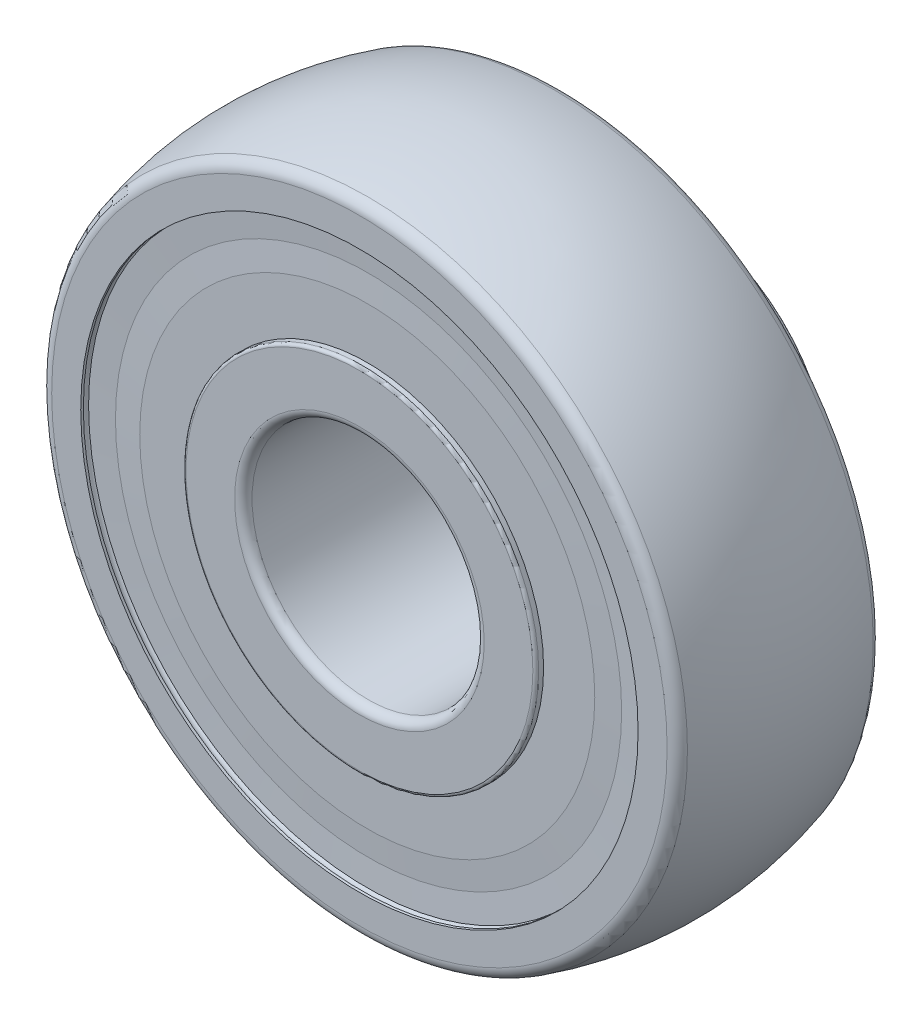
from build123d import *

# Parameters (mm, degrees)
BALL_PATTERN_COUNT              = 7
M3_SET_SCREW_HOLE_PATTERN_COUNT = 2
M3_SET_SCREW_HOLE_PATTERN_ANGLE = 90


with BuildPart() as part:
    # Sketch1 → Bearing Body (revolve)
    with BuildSketch(Plane(origin=(0, 0, 0), x_dir=(0, 0, -1), z_dir=(1, 0, 0))):
        with BuildLine():
            Line((-3.2, 4), (3.2, 4))
            Line((3.2, 4), (7.05, 4))
            ThreePointArc((7.05, 4), (7.262132034, 4.087867966), (7.35, 4.3))
            Line((7.35, 4.3), (7.35, 5.35))
            ThreePointArc((7.35, 5.35), (7.320710678, 5.420710678), (7.25, 5.45))
            Line((7.25, 5.45), (3.6, 5.45))
            Line((3.6, 5.45), (3.5, 5.55))
            Line((3.5, 5.55), (3.5, 5.975))
            ThreePointArc((3.5, 5.975), (3.470710678, 6.045710678), (3.4, 6.075))
            Line((3.4, 6.075), (3.23, 6.075))
            Line((3.23, 6.075), (3.23, 7.8375))
            Line((3.23, 7.8375), (3.185, 8.71875))
            Line((3.185, 8.71875), (3.23, 9.6))
            Line((3.23, 9.6), (3.14, 9.6))
            Line((3.14, 9.6), (3.05, 8.71875))
            Line((3.05, 8.71875), (3.05, 7.8375))
            Line((3.05, 7.8375), (3.14, 6.075))
            Line((3.14, 6.075), (1.520728526, 6.075))
            ThreePointArc((1.520728526, 6.075), (0, 5.3655), (-1.520728526, 6.075))
            Line((-1.520728526, 6.075), (-3.14, 6.075))
            Line((-3.14, 6.075), (-3.05, 7.8375))
            Line((-3.05, 7.8375), (-3.05, 8.71875))
            Line((-3.05, 8.71875), (-3.14, 9.6))
            Line((-3.14, 9.6), (-3.23, 9.6))
            Line((-3.23, 9.6), (-3.185, 8.71875))
            Line((-3.185, 8.71875), (-3.23, 7.8375))
            Line((-3.23, 7.8375), (-3.23, 6.075))
            Line((-3.23, 6.075), (-3.4, 6.075))
            ThreePointArc((-3.4, 6.075), (-3.470710678, 6.045710678), (-3.5, 5.975))
            Line((-3.5, 5.975), (-3.5, 4.3))
            ThreePointArc((-3.5, 4.3), (-3.412132034, 4.087867966), (-3.2, 4))
        make_face()
        with BuildLine():
            Line((-3.5, 9.6), (-3.5, 10.600290833))
            ThreePointArc((-3.5, 10.600290833), (-3.416656964, 10.850174515), (-3.2, 11))
            ThreePointArc((-3.2, 11), (0, 11.456002793), (3.2, 11))
            ThreePointArc((3.2, 11), (3.416656964, 10.850174515), (3.5, 10.600290833))
            Line((3.5, 10.600290833), (3.5, 9.6))
            Line((3.5, 9.6), (3.41, 9.6))
            ThreePointArc((3.41, 9.6), (3.23, 9.78), (3.05, 9.6))
            Line((3.05, 9.6), (2.908938415, 8.8))
            Line((2.908938415, 8.8), (1.354894922, 8.8))
            ThreePointArc((1.354894922, 8.8), (0, 9.3345), (-1.354894922, 8.8))
            Line((-1.354894922, 8.8), (-2.908938415, 8.8))
            Line((-2.908938415, 8.8), (-3.05, 9.6))
            ThreePointArc((-3.05, 9.6), (-3.23, 9.78), (-3.41, 9.6))
            Line((-3.41, 9.6), (-3.5, 9.6))
        make_face()
    revolve(axis=Axis((0, 0, 3.5), (0, 0, -1)))

    # Sketch6 → M3 Set Screw Hole (revolve, cut)
    with BuildSketch(Plane(origin=(0, 5.45, -5.425), x_dir=(0, 0, 1), z_dir=(1, 0, 0))):
        Polygon((0, 0), (0, 8.251075774), (1.25, 7.5), (1.25, 0), align=None)
    m3_set_screw_hole = revolve(axis=Axis((0, 11.8, -5.425), (0, -1, 0)), mode=Mode.SUBTRACT)

    # M3 Set Screw Hole Pattern: M3 Set Screw Hole ×2 about axis
    m3_set_screw_hole_pattern_axis = Axis((0, 0, -7.05), (0, 0, -1))
    for i in range(1, M3_SET_SCREW_HOLE_PATTERN_COUNT):
        add(m3_set_screw_hole.rotate(m3_set_screw_hole_pattern_axis, i * M3_SET_SCREW_HOLE_PATTERN_ANGLE / (M3_SET_SCREW_HOLE_PATTERN_COUNT - 1)), mode=Mode.SUBTRACT)


with BuildPart() as body_2:
    # Sketch2 → Ball (revolve)
    with BuildSketch(Plane(origin=(0, 0, 0), x_dir=(0, 0, -1), z_dir=(1, 0, 0))):
        with BuildLine():
            Line((1.9845, 7.35), (-1.9845, 7.35))
            ThreePointArc((-1.9845, 7.35), (0, 5.3655), (1.9845, 7.35))
        make_face()
    revolve(axis=Axis((0, 7.35, -1.9845), (0, 0, 1)))


with BuildPart() as ball_pattern_1:
    # Ball Pattern: pattern copy
    add(body_2.part.rotate(Axis((0, 0, -7.05), (0, 0, 1)), 1 * 360 / BALL_PATTERN_COUNT))


with BuildPart() as ball_pattern_2:
    # Ball Pattern: pattern copy
    add(body_2.part.rotate(Axis((0, 0, -7.05), (0, 0, 1)), 2 * 360 / BALL_PATTERN_COUNT))


with BuildPart() as ball_pattern_3:
    # Ball Pattern: pattern copy
    add(body_2.part.rotate(Axis((0, 0, -7.05), (0, 0, 1)), 3 * 360 / BALL_PATTERN_COUNT))


with BuildPart() as ball_pattern_4:
    # Ball Pattern: pattern copy
    add(body_2.part.rotate(Axis((0, 0, -7.05), (0, 0, 1)), 4 * 360 / BALL_PATTERN_COUNT))


with BuildPart() as ball_pattern_5:
    # Ball Pattern: pattern copy
    add(body_2.part.rotate(Axis((0, 0, -7.05), (0, 0, 1)), 5 * 360 / BALL_PATTERN_COUNT))


with BuildPart() as ball_pattern_6:
    # Ball Pattern: pattern copy
    add(body_2.part.rotate(Axis((0, 0, -7.05), (0, 0, 1)), 6 * 360 / BALL_PATTERN_COUNT))


solid = Compound([part.part, body_2.part, ball_pattern_1.part, ball_pattern_2.part, ball_pattern_3.part, ball_pattern_4.part, ball_pattern_5.part, ball_pattern_6.part])
